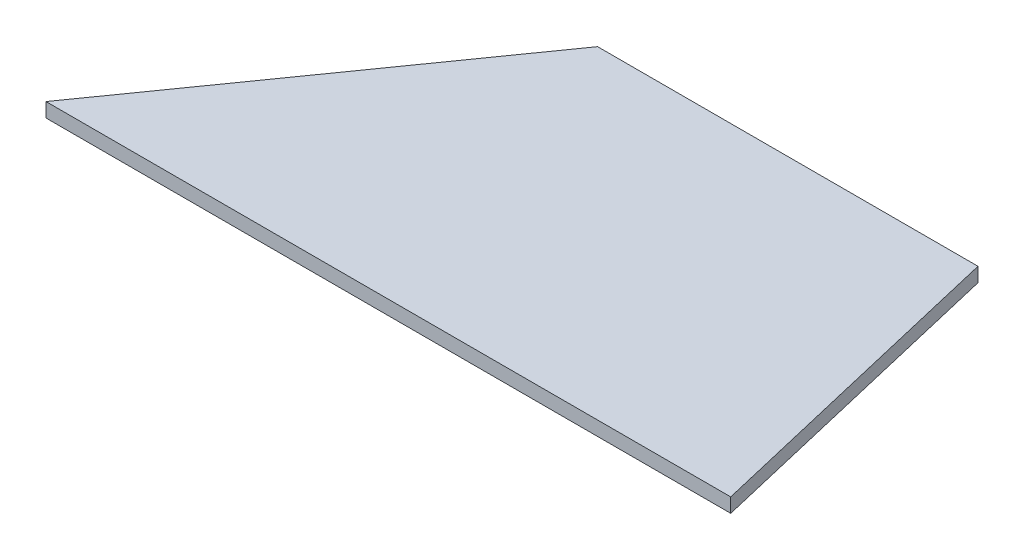
from build123d import *

# Parameters (mm, degrees)
BOSS_EXTRUDE1_DEPTH = 4.7625


with BuildPart() as part:
    # Sketch2 → Boss-Extrude1 (new body)
    with BuildSketch(Plane(origin=(0, 0, 0), x_dir=(1, 0, 0), z_dir=(0, 1, 0))):
        Polygon((228.6, 0), (203.2, 107.95), (76.2, 107.95), (0, 0), align=None)
    extrude(amount=BOSS_EXTRUDE1_DEPTH)


solid = part.part
